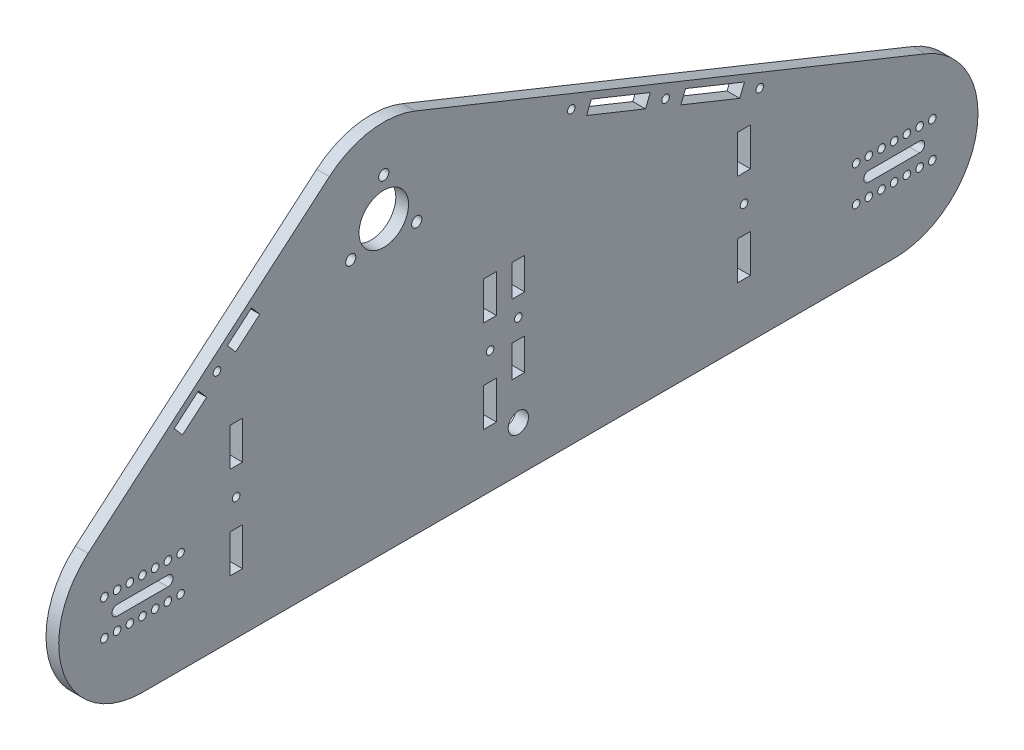
from build123d import *

# Parameters (mm, degrees)
SCHIZZO3_R                   = 1.5
ESTRUSIONE_ESTRUSIONE1_DEPTH = 5
SCHIZZO2_R                   = 2
SCHIZZO2_R_2                 = 9.75
TAGLIO_ESTRUSIONE1_DEPTH     = 6
TAGLIO_ESTRUSIONE2_DEPTH     = 6
SCHIZZO6_R                   = 1.5
SCHIZZO6_R_2                 = 4
SCHIZZO6_W                   = 5
SCHIZZO6_H                   = 15
SCHIZZO6_H_2                 = 12.5
TAGLIO_ESTRUSIONE3_DEPTH     = 6
SCHIZZO7_R                   = 1.5
TAGLIO_ESTRUSIONE4_DEPTH     = 6


with BuildPart() as part:
    # Schizzo3 → Estrusione-Estrusione1 (new body)
    with BuildSketch(Plane(origin=(0, 0, 0), x_dir=(0, 0, -1), z_dir=(1, 0, 0))):
        with BuildLine():
            Line((-95, -33), (201, -33))
            ThreePointArc((201, -33), (233.396512744, -6.282194046), (213.334616938, 30.608123513))
            Line((213.334616938, 30.608123513), (12.334616938, 111.608123513))
            ThreePointArc((12.334616938, 111.608123513), (-5.305430843, 113.570729245), (-21.410737295, 106.111358555))
            Line((-21.410737295, 106.111358555), (-116.410737295, 25.111358555))
            ThreePointArc((-116.410737295, 25.111358555), (-125.96509997, -11.408881796), (-95, -33))
        make_face()
        with Locations((-65.666686189, 61.806607259)):
            Circle(SCHIZZO3_R, mode=Mode.SUBTRACT)
        with Locations((110.965735584, 66.470529041)):
            Circle(SCHIZZO3_R, mode=Mode.SUBTRACT)
        with Locations((73.86497981, 81.421579875)):
            Circle(SCHIZZO3_R, mode=Mode.SUBTRACT)
        with Locations((148.066491357, 51.519478207)):
            Circle(SCHIZZO3_R, mode=Mode.SUBTRACT)
    extrude(amount=ESTRUSIONE_ESTRUSIONE1_DEPTH)

    # Schizzo2 → Taglio-Estrusione1 (cut, through all)
    with BuildSketch(Plane(origin=(0, 0, 0), x_dir=(0, 0, -1), z_dir=(1, 0, 0))):
        with Locations((-95, 0)):
            Circle(SCHIZZO2_R)
        with Locations((201, 0)):
            Circle(SCHIZZO2_R)
        with Locations((12.990381057, 73.5)):
            Circle(SCHIZZO2_R)
        with Locations((-12.990381057, 73.5)):
            Circle(SCHIZZO2_R)
        with Locations((0, 96)):
            Circle(SCHIZZO2_R)
        with Locations((0, 81)):
            Circle(SCHIZZO2_R_2)
    extrude(amount=TAGLIO_ESTRUSIONE1_DEPTH, mode=Mode.SUBTRACT)

    # Schizzo4 → Taglio-Estrusione2 (cut, through all)
    with BuildSketch(Plane(origin=(0, 0, 0), x_dir=(0, 0, -1), z_dir=(1, 0, 0))):
        Polygon((104.943784553, 71.592648309), (103.074903199, 66.955053837), (79.886930841, 76.299460608), (81.755812195, 80.93705508), align=None)
        Polygon((118.856567968, 65.986004246), (116.987686614, 61.348409774), (140.175658973, 52.004003003), (142.044540327, 56.641597475), align=None)
        Polygon((-82.507716927, 50.732778486), (-72.995838686, 58.842906249), (-69.751787581, 55.038154953), (-79.263665822, 46.92802719), align=None)
        Polygon((-61.581584798, 68.575059565), (-58.337533692, 64.770308269), (-48.825655452, 72.880436032), (-52.069706557, 76.685187328), align=None)
    extrude(amount=TAGLIO_ESTRUSIONE2_DEPTH, mode=Mode.SUBTRACT)

    # Schizzo6 → Taglio-Estrusione3 (cut, through all)
    with BuildSketch(Plane(origin=(5, 0, 0), x_dir=(0, 0, -1), z_dir=(1, 0, 0))):
        with Locations((41.87, 15.17)):
            Circle(SCHIZZO6_R)
        with Locations((-58.13, 15.17)):
            Circle(SCHIZZO6_R)
        with Locations((141.87, 15.17)):
            Circle(SCHIZZO6_R)
        with Locations((53, -15)):
            Circle(SCHIZZO6_R_2)
        with Locations((53, 20.84)):
            Circle(SCHIZZO6_R)
        with Locations((41.87, -3)):
            Rectangle(SCHIZZO6_W, SCHIZZO6_H)
        with Locations((41.87, 33.34)):
            Rectangle(SCHIZZO6_W, SCHIZZO6_H)
        with Locations((141.87, 33.34)):
            Rectangle(SCHIZZO6_W, SCHIZZO6_H)
        with Locations((141.87, -3)):
            Rectangle(SCHIZZO6_W, SCHIZZO6_H)
        with Locations((-58.13, -3)):
            Rectangle(SCHIZZO6_W, SCHIZZO6_H)
        with Locations((-58.13, 33.34)):
            Rectangle(SCHIZZO6_W, SCHIZZO6_H)
        with Locations((53, 34.59)):
            Rectangle(SCHIZZO6_W, SCHIZZO6_H_2)
        with Locations((53, 7.09)):
            Rectangle(SCHIZZO6_W, SCHIZZO6_H_2)
    extrude(amount=-TAGLIO_ESTRUSIONE3_DEPTH, mode=Mode.SUBTRACT)

    # Schizzo7 → Taglio-Estrusione4 (cut, through all)
    with BuildSketch(Plane(origin=(0, 0, 0), x_dir=(0, 0, -1), z_dir=(1, 0, 0))):
        with Locations((-95, 7)):
            Circle(SCHIZZO7_R)
        with Locations((-90, 7)):
            Circle(SCHIZZO7_R)
        with Locations((-85, 7)):
            Circle(SCHIZZO7_R)
        with Locations((-80, 7)):
            Circle(SCHIZZO7_R)
        with Locations((-100, 7)):
            Circle(SCHIZZO7_R)
        with Locations((-105, 7)):
            Circle(SCHIZZO7_R)
        with Locations((-110, 7)):
            Circle(SCHIZZO7_R)
        with Locations((-80, -7)):
            Circle(SCHIZZO7_R)
        with Locations((-85, -7)):
            Circle(SCHIZZO7_R)
        with Locations((-90, -7)):
            Circle(SCHIZZO7_R)
        with Locations((-95, -7)):
            Circle(SCHIZZO7_R)
        with Locations((-100, -7)):
            Circle(SCHIZZO7_R)
        with Locations((-105, -7)):
            Circle(SCHIZZO7_R)
        with Locations((-110, -7)):
            Circle(SCHIZZO7_R)
        with Locations((216, -7)):
            Circle(SCHIZZO7_R)
        with Locations((211, -7)):
            Circle(SCHIZZO7_R)
        with Locations((206, -7)):
            Circle(SCHIZZO7_R)
        with Locations((201, -7)):
            Circle(SCHIZZO7_R)
        with Locations((196, -7)):
            Circle(SCHIZZO7_R)
        with Locations((191, -7)):
            Circle(SCHIZZO7_R)
        with Locations((186, -7)):
            Circle(SCHIZZO7_R)
        with Locations((186, 7)):
            Circle(SCHIZZO7_R)
        with Locations((191, 7)):
            Circle(SCHIZZO7_R)
        with Locations((196, 7)):
            Circle(SCHIZZO7_R)
        with Locations((201, 7)):
            Circle(SCHIZZO7_R)
        with Locations((206, 7)):
            Circle(SCHIZZO7_R)
        with Locations((211, 7)):
            Circle(SCHIZZO7_R)
        with Locations((216, 7)):
            Circle(SCHIZZO7_R)
        with BuildLine():
            Line((-105, 2), (-85, 2))
            ThreePointArc((-85, 2), (-83, 0), (-85, -2))
            Line((-85, -2), (-105, -2))
            ThreePointArc((-105, -2), (-107, 0), (-105, 2))
        make_face()
        with BuildLine():
            Line((191, 2), (211, 2))
            ThreePointArc((211, 2), (213, 0), (211, -2))
            Line((211, -2), (191, -2))
            ThreePointArc((191, -2), (189, 0), (191, 2))
        make_face()
    extrude(amount=TAGLIO_ESTRUSIONE4_DEPTH, mode=Mode.SUBTRACT)


solid = part.part
